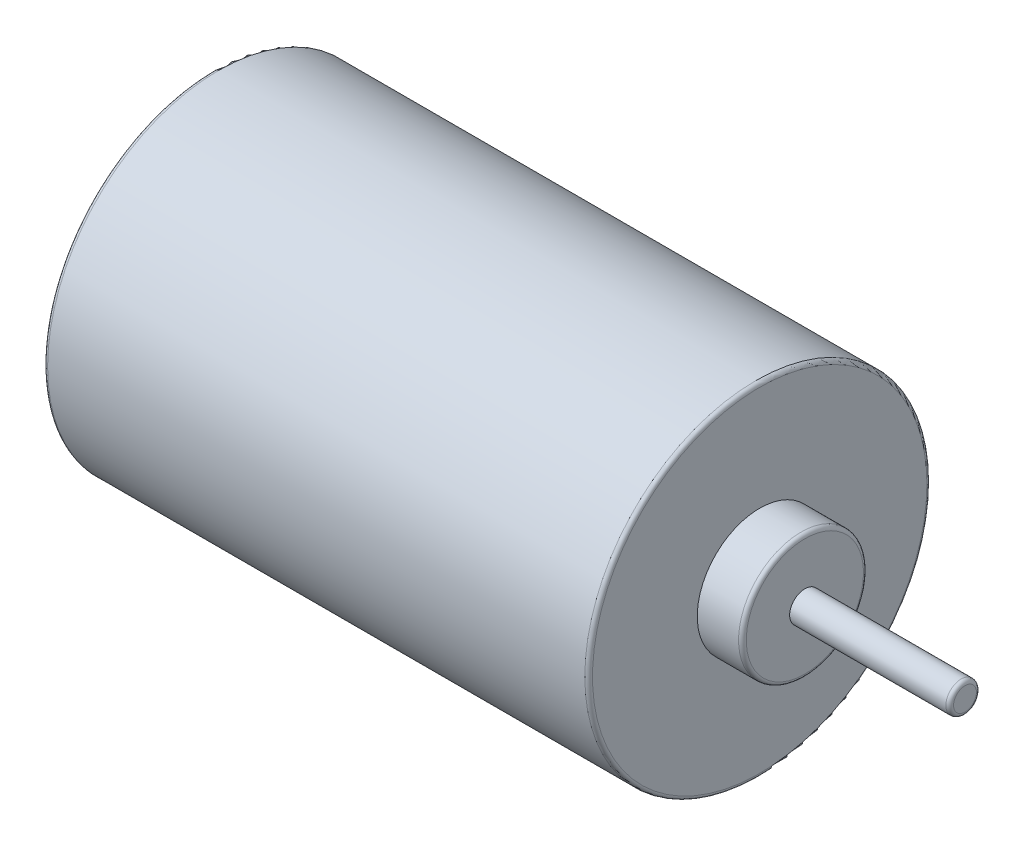
from build123d import *

# Parameters (mm, degrees)
CROQUIS1_R              = 17.8
SALIENTE_EXTRUIR1_DEPTH = 56.7
CROQUIS2_R              = 6
SALIENTE_EXTRUIR2_DEPTH = 1
CROQUIS3_R              = 5
SALIENTE_EXTRUIR3_DEPTH = 1
CROQUIS4_R              = 6.5
SALIENTE_EXTRUIR4_DEPTH = 4.7
CROQUIS5_R              = 1.5875
SALIENTE_EXTRUIR5_DEPTH = 16.66
REDONDEO1_R             = 0.4


with BuildPart() as part:
    # Croquis1 → Saliente-Extruir1 (new body)
    with BuildSketch(Plane(origin=(0, 0, 0), x_dir=(0, 0, -1), z_dir=(1, 0, 0))):
        Circle(CROQUIS1_R)
    extrude(amount=SALIENTE_EXTRUIR1_DEPTH)

    # Croquis2 → Saliente-Extruir2 (add)
    with BuildSketch(Plane.ZY):
        Circle(CROQUIS2_R)
    extrude(amount=SALIENTE_EXTRUIR2_DEPTH)

    # Croquis3 → Saliente-Extruir3 (add)
    with BuildSketch(Plane.ZY.offset(1)):
        Circle(CROQUIS3_R)
    extrude(amount=SALIENTE_EXTRUIR3_DEPTH)

    # Croquis4 → Saliente-Extruir4 (add)
    with BuildSketch(Plane(origin=(56.7, 0, 0), x_dir=(0, 0, -1), z_dir=(1, 0, 0))):
        Circle(CROQUIS4_R)
    extrude(amount=SALIENTE_EXTRUIR4_DEPTH)

    # Croquis5 → Saliente-Extruir5 (add)
    with BuildSketch(Plane(origin=(61.4, 0, 0), x_dir=(0, 0, -1), z_dir=(1, 0, 0))):
        Circle(CROQUIS5_R)
    extrude(amount=SALIENTE_EXTRUIR5_DEPTH)

    # Redondeo1
    redondeo1_edges = [part.edges().sort_by_distance(p)[0] for p in [
        (-2, 0, -5),
        (61.4, 0, 6.5),
        (0, 0, 17.8),
        (78.06, 0, 1.5875),
        (56.7, 0, 17.8),
        (-1, 0, -6),
    ]]
    fillet(redondeo1_edges, radius=REDONDEO1_R)


solid = part.part
